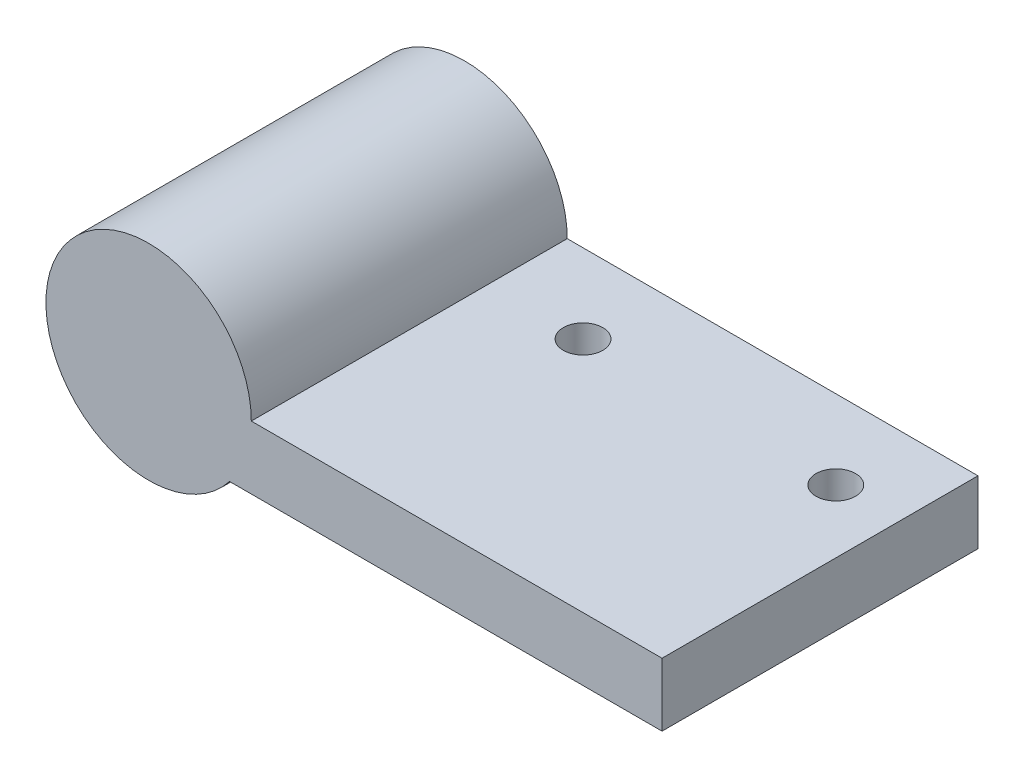
from build123d import *

# Parameters (mm, degrees)
SKETCH_1_R          = 4.15
EXTRUDE_1_DEPTH     = 20
SKETCH_2_R          = 4.923200542
EXTRUDE_2_DEPTH     = 3
SKETCH_3_R          = 1.25
CUT_EXTRUDE_1_DEPTH = 13


with BuildPart() as part:
    # Эскиз1 → Бобышка-Вытянуть1 (new body)
    with BuildSketch(Plane.XY):
        with BuildLine():
            Line((5.123475383, -4), (32.5, -4))
            Line((32.5, -4), (32.5, 0))
            Line((32.5, 0), (6.5, 0))
            ThreePointArc((6.5, 0), (-6.146242348, 2.115113473), (5.123475383, -4))
        make_face()
        Circle(SKETCH_1_R, mode=Mode.SUBTRACT)
    extrude(amount=EXTRUDE_1_DEPTH)

    # Эскиз2 → Бобышка-Вытянуть2 (add)
    with BuildSketch(Plane.XY.offset(20)):
        Circle(SKETCH_2_R)
    extrude(amount=-EXTRUDE_2_DEPTH)

    # Эскиз3 → Вырез-Вытянуть1 (cut)
    with BuildSketch(Plane(origin=(0, 0, 0), x_dir=(1, 0, 0), z_dir=(0, 1, 0))):
        with Locations((12.5, -5)):
            Circle(SKETCH_3_R)
        with Locations((28.5, -5)):
            Circle(SKETCH_3_R)
    extrude(amount=-CUT_EXTRUDE_1_DEPTH, mode=Mode.SUBTRACT)


solid = part.part
